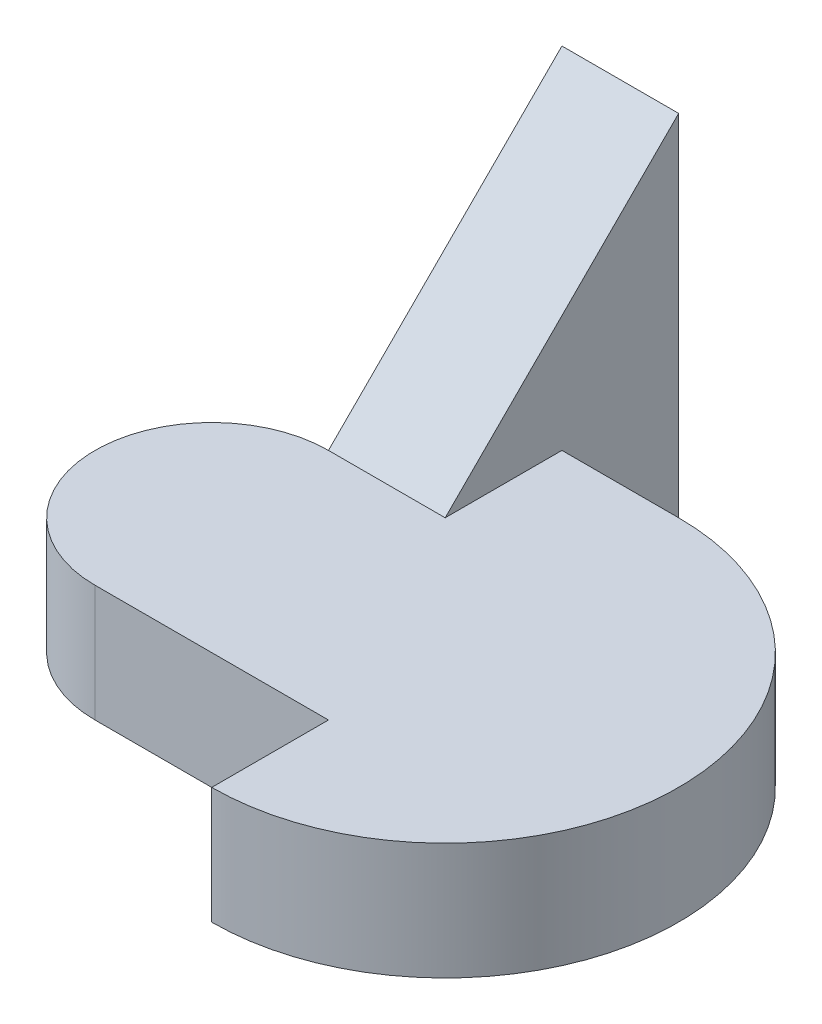
from build123d import *

# Parameters (mm, degrees)
EXTRUDE_1_DEPTH     = 5
EXTRUDE_2_DEPTH     = 15
CUT_EXTRUDE_1_DEPTH = 15
SCALE_1_SCALE       = 0.2


with BuildPart() as part:
    # 草圖1 → 填料-伸長1 (new body)
    with BuildSketch(Plane(origin=(0, 0, 0), x_dir=(1, 0, 0), z_dir=(0, 1, 0))):
        with BuildLine():
            ThreePointArc((-10, 5), (-15, 0), (-10, -5))
            Line((-10, -5), (0, -5))
            Line((0, -5), (0, -10))
            ThreePointArc((0, -10), (10, 0), (0, 10))
            Line((0, 10), (-5, 10))
            Line((-5, 10), (-5, 5))
            Line((-5, 5), (-10, 5))
        make_face()
    extrude(amount=EXTRUDE_1_DEPTH)

    # 草圖1<3> → 填料-伸長2 (add)
    with BuildSketch(Plane(origin=(0, 0, 0), x_dir=(1, 0, 0), z_dir=(0, 1, 0))):
        Polygon((-10, 15), (-10, 5), (-5, 5), (-5, 10), (-5, 15), align=None)
    extrude(amount=EXTRUDE_2_DEPTH)

    # 草圖2 → 除料-伸長1 (cut)
    with BuildSketch(Plane.ZY.offset(10)):
        Polygon((-15, 15), (-5, 5), (-5, 15), align=None)
    extrude(amount=-CUT_EXTRUDE_1_DEPTH, mode=Mode.SUBTRACT)


with BuildPart() as part_1:
    # 縮放比例1: scaled about (-2.662553627, 3.192220208, -3.016102333)
    add(part.part.scale(SCALE_1_SCALE).moved(Location((-2.130042902, 2.553776166, -2.412881866))))


solid = part_1.part
